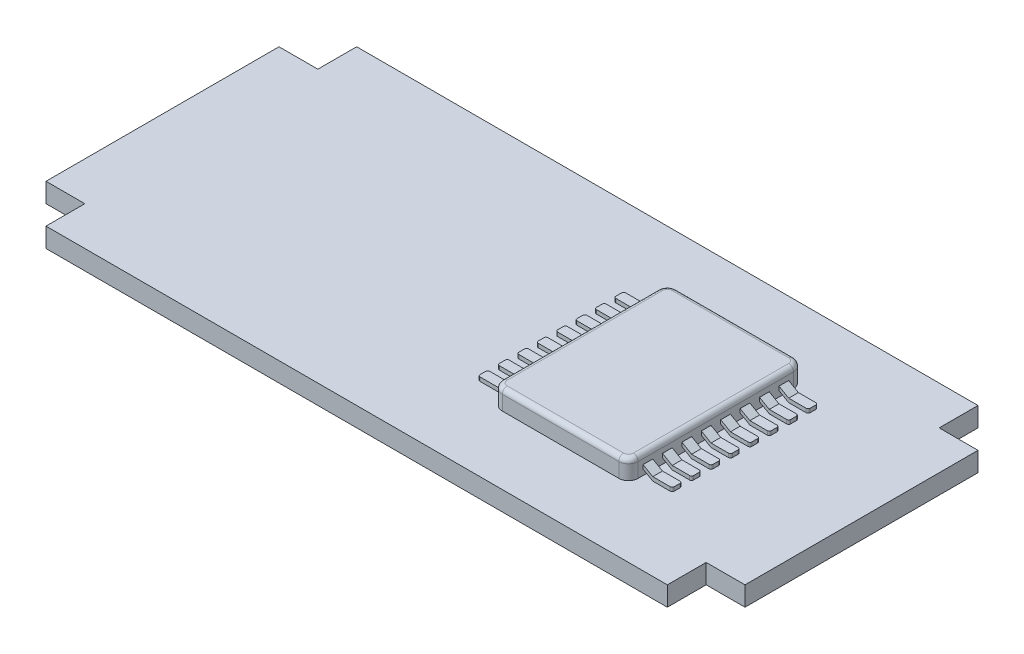
from build123d import *

# Parameters (mm, degrees)
ESTRUSIONE_ESTRUSIONE1_DEPTH = 1
SCHIZZO2_W                   = 7
SCHIZZO2_H                   = 9
ESTRUSIONE_ESTRUSIONE2_DEPTH = 1
RACCORDO2_R                  = 0.5
RACCORDO3_R                  = 0.25
SCHIZZO4_W                   = 1
SCHIZZO4_H                   = 8
ESTRUSIONE_ESTRUSIONE6_DEPTH = 0.2
ESTRUSIONE_ESTRUSIONE7_DEPTH = 8
SCHIZZO6_W                   = 1.5
SCHIZZO6_H                   = 0.5
SCHIZZO6_H_2                 = 0.25
TAGLIO_ESTRUSIONE1_DEPTH     = 1
RACCORDO6_R                  = 0.1
RACCORDO6_OF_SPECCHIA1_R     = 0.1


with BuildPart() as part:
    # Schizzo1 → Estrusione-Estrusione1 (new body)
    with BuildSketch(Plane(origin=(0, 0, 0), x_dir=(1, 0, 0), z_dir=(0, 1, 0))):
        Polygon((-16, -8), (-16, -6), (-18, -6), (-18, 6), (-16, 6), (-16, 8), (16, 8), (16, 6), (18, 6), (18, -6), (16, -6), (16, -8), align=None)
    extrude(amount=ESTRUSIONE_ESTRUSIONE1_DEPTH)

    # Schizzo2 → Estrusione-Estrusione2 (add)
    with BuildSketch(Plane(origin=(0, 1, 0), x_dir=(1, 0, 0), z_dir=(0, 1, 0))):
        with Locations((7, 0)):
            Rectangle(SCHIZZO2_W, SCHIZZO2_H)
    extrude(amount=ESTRUSIONE_ESTRUSIONE2_DEPTH)

    # Raccordo2
    raccordo2_edges = [part.edges().sort_by_distance(p)[0] for p in [
        (10.5, 1.5, 4.5),
        (10.5, 1.5, -4.5),
        (3.5, 1.5, -4.5),
        (3.5, 1.5, 4.5),
    ]]
    fillet(raccordo2_edges, radius=RACCORDO2_R)

    # Raccordo3
    raccordo3_edges = [part.edges().sort_by_distance(p)[0] for p in [
        (3.5, 2, 0),
        (7, 2, -4.5),
        (10.5, 2, 0),
        (7, 2, 4.5),
        (3.646446609, 2, 4.353553391),
        (10.353553391, 2, 4.353553391),
        (10.353553391, 2, -4.353553391),
        (3.646446609, 2, -4.353553391),
    ]]
    fillet(raccordo3_edges, radius=RACCORDO3_R)

    # Schizzo4 → Estrusione-Estrusione6 (add)
    with BuildSketch(Plane(origin=(0, 1, 0), x_dir=(1, 0, 0), z_dir=(0, 1, 0))):
        with Locations((2.5, 0)):
            Rectangle(SCHIZZO4_W, SCHIZZO4_H)
    estrusione_estrusione6 = extrude(amount=ESTRUSIONE_ESTRUSIONE6_DEPTH)

    # Schizzo5 → Estrusione-Estrusione7 (add)
    with BuildSketch(Plane.XY.offset(4)):
        Polygon((3, 1), (3, 1.2), (3.5, 1.488675135), (3.5, 1.288675135), align=None)
    estrusione_estrusione7 = extrude(amount=-ESTRUSIONE_ESTRUSIONE7_DEPTH)

    # Schizzo6 → Taglio-Estrusione1 (cut)
    with BuildSketch(Plane(origin=(0, 1, 0), x_dir=(1, 0, 0), z_dir=(0, 1, 0))):
        with Locations((2.75, -3)):
            Rectangle(SCHIZZO6_W, SCHIZZO6_H)
        with Locations((2.75, -2)):
            Rectangle(SCHIZZO6_W, SCHIZZO6_H)
        with Locations((2.75, -1)):
            Rectangle(SCHIZZO6_W, SCHIZZO6_H)
        with Locations((2.75, 0)):
            Rectangle(SCHIZZO6_W, SCHIZZO6_H)
        with Locations((2.75, 1)):
            Rectangle(SCHIZZO6_W, SCHIZZO6_H)
        with Locations((2.75, 2)):
            Rectangle(SCHIZZO6_W, SCHIZZO6_H)
        with Locations((2.75, 3)):
            Rectangle(SCHIZZO6_W, SCHIZZO6_H)
        with Locations((2.75, 3.875)):
            Rectangle(SCHIZZO6_W, SCHIZZO6_H_2)
        with Locations((2.75, -3.875)):
            Rectangle(SCHIZZO6_W, SCHIZZO6_H_2)
    taglio_estrusione1 = extrude(amount=TAGLIO_ESTRUSIONE1_DEPTH, mode=Mode.SUBTRACT)

    # Raccordo6
    raccordo6_edges = [part.edges().sort_by_distance(p)[0] for p in [
        (2, 1.1, 1.75),
        (2, 1.1, 2.25),
        (2, 1.1, 0.75),
        (2, 1.1, 1.25),
        (2, 1.1, -0.25),
        (2, 1.1, 0.25),
        (2, 1.1, -1.25),
        (2, 1.1, -0.75),
        (2, 1.1, 3.75),
        (2, 1.1, -3.75),
        (2, 1.1, -3.25),
        (2, 1.1, -2.75),
        (2, 1.1, -2.25),
        (2, 1.1, -1.75),
        (2, 1.1, 2.75),
        (2, 1.1, 3.25),
    ]]
    fillet(raccordo6_edges, radius=RACCORDO6_R)

    # Specchia1: Estrusione-Estrusione6, Estrusione-Estrusione7, Taglio-Estrusione1 across plane
    add(estrusione_estrusione6.mirror(Plane.ZY.offset(-7)))
    add(estrusione_estrusione7.mirror(Plane.ZY.offset(-7)))
    add(taglio_estrusione1.mirror(Plane.ZY.offset(-7)), mode=Mode.SUBTRACT)

    # Raccordo6 of Specchia1
    raccordo6_of_specchia1_edges = [part.edges().sort_by_distance(p)[0] for p in [
        (12, 1.1, 1.75),
        (12, 1.1, 2.25),
        (12, 1.1, 0.75),
        (12, 1.1, 1.25),
        (12, 1.1, -0.25),
        (12, 1.1, 0.25),
        (12, 1.1, -1.25),
        (12, 1.1, -0.75),
        (12, 1.1, 3.75),
        (12, 1.1, -3.75),
        (12, 1.1, -3.25),
        (12, 1.1, -2.75),
        (12, 1.1, -2.25),
        (12, 1.1, -1.75),
        (12, 1.1, 2.75),
        (12, 1.1, 3.25),
    ]]
    fillet(raccordo6_of_specchia1_edges, radius=RACCORDO6_OF_SPECCHIA1_R)


solid = part.part
